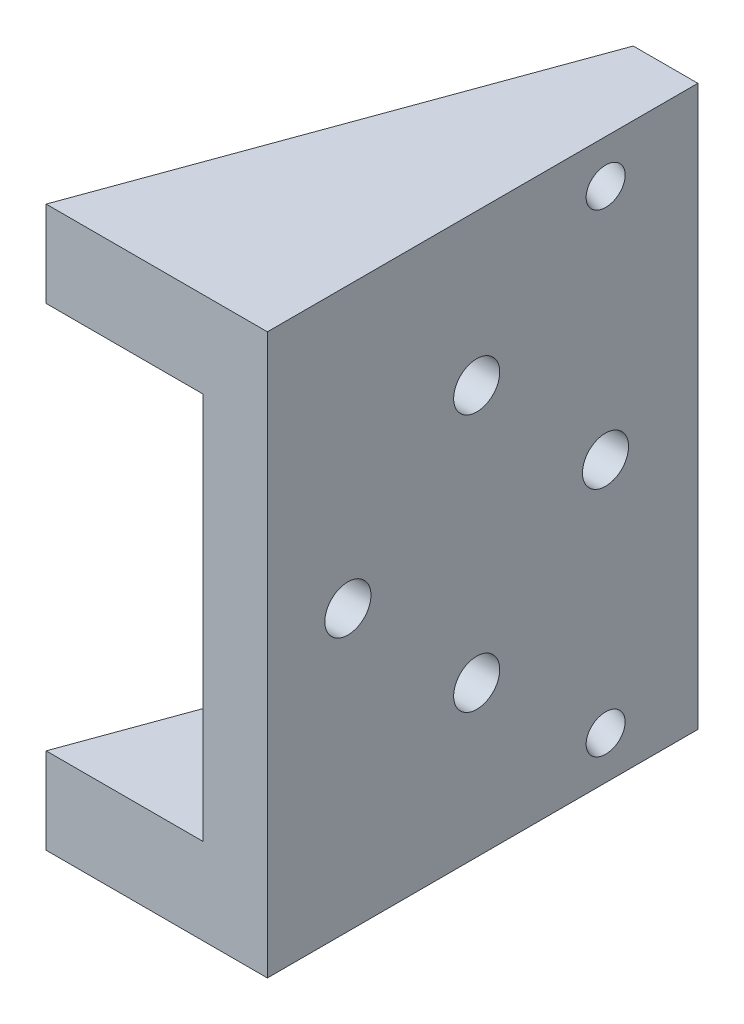
from build123d import *

# Parameters (mm, degrees)
BOSS_EXTRUDE1_DEPTH       = 20.6375
M3_CLEARANCE_HOLE1_D      = 3.4
CUT_EXTRUDE1_DEPTH        = 14.2875
CUT_EXTRUDE1_DEPTH_BACK   = 14.2875
F_6_32_TAPPED_HOLE1_D     = 2.7051
F_6_32_TAPPED_HOLE1_DEPTH = 8.382
F_6_32_TAPPED_HOLE1_TIP   = 0.81269403


with BuildPart() as part:
    # Sketch1 → Boss-Extrude1 (new body, symmetric)
    with BuildSketch(Plane(origin=(0, 0, 0), x_dir=(1, 0, 0), z_dir=(0, 1, 0))):
        Polygon((0, 0), (-11.556054938, -31.75), (4.7625, -31.75), (4.7625, 0), align=None)
    extrude(amount=BOSS_EXTRUDE1_DEPTH, both=True)

    # M3 Clearance Hole1 (through all)
    with Locations(Plane(origin=(4.7625, 0, 0), x_dir=(0, 0, -1), z_dir=(1, 0, 0))):
        with Locations((-16.3125, 9.5), (-6.8125, 0), (-16.3125, -9.5), (-25.8125, 0)):
            Hole(M3_CLEARANCE_HOLE1_D / 2)

    # Sketch15 → Cut-Extrude1 (cut, two sides)
    with BuildSketch(Plane(origin=(0, 0, 0), x_dir=(1, 0, 0), z_dir=(0, 1, 0))) as cut_extrude1_sk:
        Polygon((-11.556054938, -31.75), (0, 0), (0, -31.75), align=None)
    extrude(amount=CUT_EXTRUDE1_DEPTH, mode=Mode.SUBTRACT)
    extrude(cut_extrude1_sk.sketch, amount=-CUT_EXTRUDE1_DEPTH_BACK, mode=Mode.SUBTRACT)

    # #6-32 Tapped Hole1
    with Locations(Plane(origin=(0, 0, 0), x_dir=(-0.342020143, 0, 0.939692621), z_dir=(-0.939692621, 0, -0.342020143))):
        with Locations((4.7625, 17.4625), (26.9875, 17.4625), (26.9875, -17.4625), (4.7625, -17.4625)):
            Hole(F_6_32_TAPPED_HOLE1_D / 2, depth=F_6_32_TAPPED_HOLE1_DEPTH)
            with Locations((0, 0, -(F_6_32_TAPPED_HOLE1_DEPTH + F_6_32_TAPPED_HOLE1_TIP / 2))):  # 118° drill point
                Cone(0, F_6_32_TAPPED_HOLE1_D / 2, F_6_32_TAPPED_HOLE1_TIP, mode=Mode.SUBTRACT)


solid = part.part
